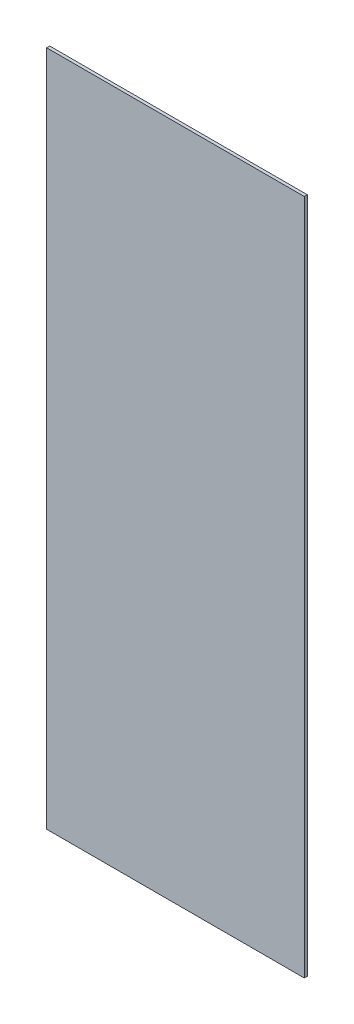
from build123d import *

# Parameters (mm, degrees)
SKETCH1_W      = 126.25
SKETCH1_H      = 331.7
EXTRUDE1_DEPTH = 1.5


with BuildPart() as part:
    # Sketch1 → Extrude1 (new body)
    with BuildSketch(Plane.XY):
        with Locations((481.3, 0)):
            Rectangle(SKETCH1_W, SKETCH1_H)
    extrude(amount=EXTRUDE1_DEPTH)


solid = part.part
